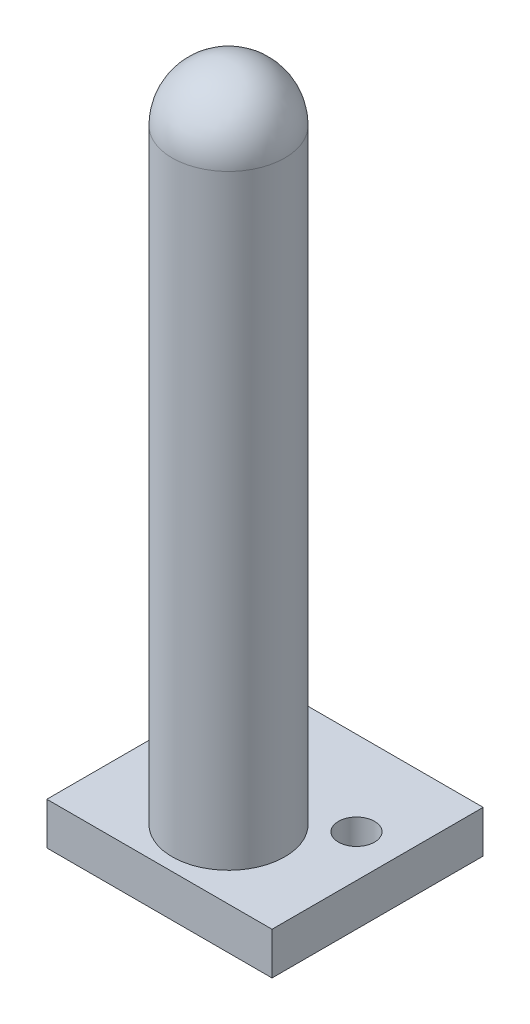
from build123d import *
from build123d.topology import SkipClean

# Parameters (mm, degrees)
SKETCH1_W           = 16
SKETCH1_H           = 3
BOSS_EXTRUDE1_DEPTH = 15
SKETCH2_R           = 1.282586005
CUT_EXTRUDE1_DEPTH  = 12
SKETCH3_R           = 4
BOSS_EXTRUDE2_DEPTH = 43


with BuildPart() as part:
    # Sketch1 → Boss-Extrude1 (new body)
    with BuildSketch(Plane.XY):
        with Locations((0, 21.58414062)):
            Rectangle(SKETCH1_W, SKETCH1_H)
    extrude(amount=BOSS_EXTRUDE1_DEPTH)

    # Sketch2 → Cut-Extrude1 (cut)
    with BuildSketch(Plane(origin=(0, 23.08414062, 0), x_dir=(1, 0, 0), z_dir=(0, 1, 0))):
        with Locations(Location((5, -6, 0), (0, 0, 270))):
            Circle(SKETCH2_R)
        with Locations(Location((-5, -6, 0), (0, 0, 270))):
            Circle(SKETCH2_R)
    extrude(amount=-CUT_EXTRUDE1_DEPTH, mode=Mode.SUBTRACT)

    # Sketch3 → Boss-Extrude2 (add)
    with BuildSketch(Plane(origin=(0, 23.08414062, 0), x_dir=(1, 0, 0), z_dir=(0, 1, 0))):
        with Locations(Location((0, -10.092270702, 0), (0, 0, 90))):
            Circle(SKETCH3_R)
    extrude(amount=BOSS_EXTRUDE2_DEPTH)

    # Sketch5 → Revolve1 (revolve)
    with SkipClean():  # the faces are left unmerged after this step: merging them gives an invalid solid
        with BuildSketch(Plane(origin=(0, 66.08414062, 0), x_dir=(1, 0, 0), z_dir=(0, 1, 0))):
            with BuildLine():
                ThreePointArc((4, -10.092270702), (2.828427125, -7.263843577), (0, -6.092270702))
                Line((0, -6.092270702), (0, -14.092270702))
                ThreePointArc((0, -14.092270702), (2.828427125, -12.920697827), (4, -10.092270702))
            make_face()
            with BuildLine():
                Line((0, -14.092270702), (0, -6.092270702))
                ThreePointArc((0, -6.092270702), (-4, -10.092270702), (0, -14.092270702))
            make_face()
        revolve(axis=Axis((0, 66.08414062, 6.092270702), (0, 0, 1)))


solid = part.part
